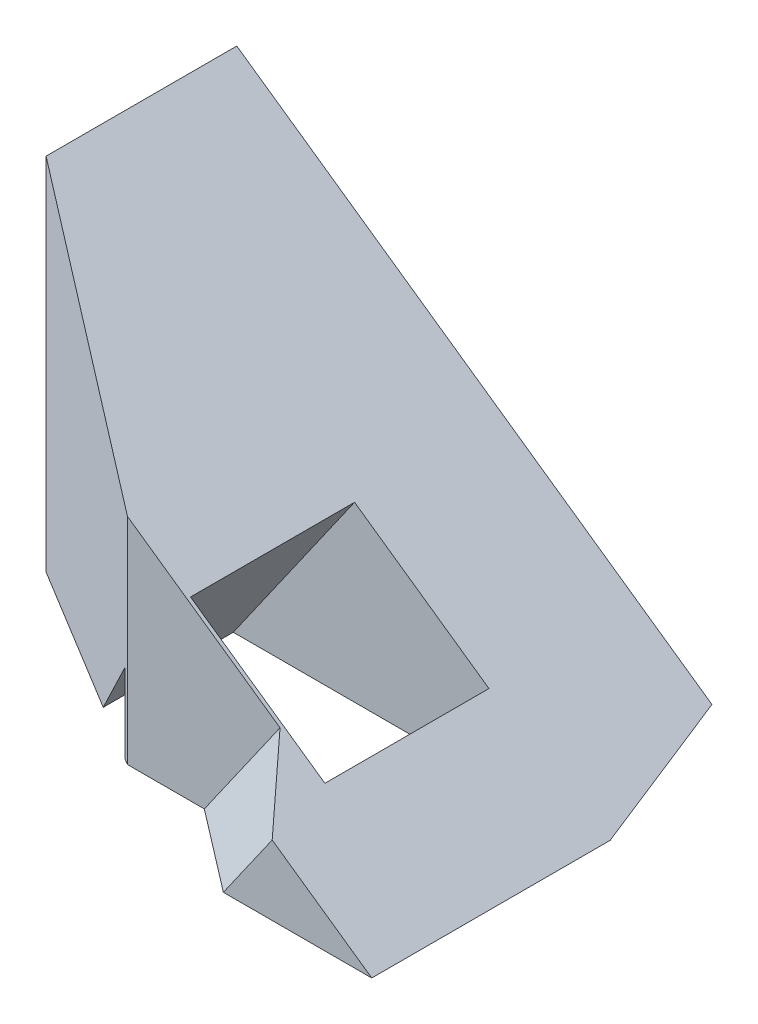
from build123d import *

# Parameters (mm, degrees)
SKIZZE1_W                       = 100
SKIZZE1_H                       = 100
AUFSATZ_LINEAR_AUSTRAGEN1_DEPTH = 50
SKIZZE2_OUTSIDE_W               = 132
SKIZZE2_OUTSIDE_H               = 82
SCHNITT_LINEAR_AUSTRAGEN1_DEPTH = 101
SKIZZE3_OUTSIDE_W               = 142.594
SKIZZE3_OUTSIDE_H               = 132
SKIZZE3_OUTSIDE_W_2             = 12
SKIZZE3_OUTSIDE_H_2             = 12
SCHNITT_LINEAR_AUSTRAGEN2_DEPTH = 58.357643635
SCHNITT_LINEAR_AUSTRAGEN3_DEPTH = 50


with BuildPart() as part:
    # Skizze1 → Aufsatz-Linear austragen1 (new body)
    with BuildSketch(Plane(origin=(0, 0, 0), x_dir=(1, 0, 0), z_dir=(0, 1, 0))):
        with Locations((50, 50)):
            Rectangle(SKIZZE1_W, SKIZZE1_H)
    extrude(amount=AUFSATZ_LINEAR_AUSTRAGEN1_DEPTH)

    # Skizze2 outside → Schnitt-Linear austragen1 (cut, through all)
    with BuildSketch(Plane.XY):
        with Locations((50, 25)):
            Rectangle(SKIZZE2_OUTSIDE_W, SKIZZE2_OUTSIDE_H)
        Polygon((0, 0), (0, 70.020753821), (100, 0), align=None, mode=Mode.SUBTRACT)
    extrude(amount=-SCHNITT_LINEAR_AUSTRAGEN1_DEPTH, mode=Mode.SUBTRACT)

    # Skizze3 outside → Schnitt-Linear austragen2 (cut, through all)
    with BuildSketch(Plane(origin=(32.898992834, 46.984631039, 0), x_dir=(0.819152044, -0.573576436, 0), z_dir=(0.573576436, 0.819152044, 0))):
        with Locations((26.618, 50)):
            Rectangle(SKIZZE3_OUTSIDE_W, SKIZZE3_OUTSIDE_H)
        Polygon((81.915204429, 37.859878609), (81.915204429, 55.30029111), (78.408084137, 65.614823426), (35.984131413, 65.614823426), (35.984131413, 51.664109902), (54.501889142, 42.446196436), (68.128544963, 42.446196436), (73.025747531, 37.859878609), align=None, mode=Mode.SUBTRACT)
        with Locations((65.828544963, 48.696196436)):
            Rectangle(SKIZZE3_OUTSIDE_W_2, SKIZZE3_OUTSIDE_H_2)
    extrude(amount=-SCHNITT_LINEAR_AUSTRAGEN2_DEPTH, mode=Mode.SUBTRACT)

    # Skizze4 → Schnitt-Linear austragen3 (cut)
    with BuildSketch(Plane(origin=(0, 0, 0), x_dir=(1, 0, 0), z_dir=(0, 1, 0))):
        Polygon((62.375467643, 65.614823426), (62.375467643, 51.664109902), (77.544326742, 42.446196436), (62.375467643, 16.747939689), (28.386649176, 16.747939689), (28.386649176, 99.890537097), (62.375467643, 99.890537097), align=None)
    extrude(amount=SCHNITT_LINEAR_AUSTRAGEN3_DEPTH, mode=Mode.SUBTRACT)


solid = part.part
